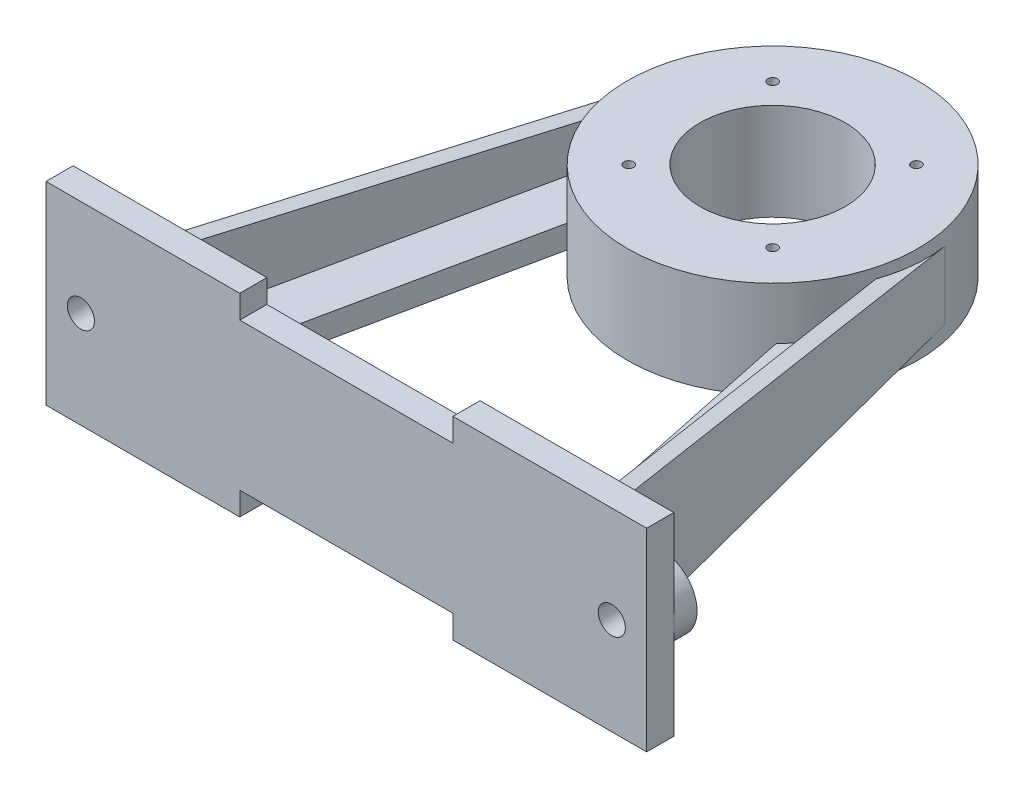
from build123d import *

# Parameters (mm, degrees)
BOSS_EXTRUDE1_DEPTH = 14
SKETCH2_R           = 75
SKETCH2_R_2         = 37.5
BOSS_EXTRUDE2_DEPTH = 25
SKETCH5_W           = 2.5
SKETCH5_H           = 50
CIRPATTERN1_COUNT   = 4
BOSS_EXTRUDE3_DEPTH = 17.5
BOSS_EXTRUDE4_DEPTH = 8
SKETCH9_R           = 7
BOSS_EXTRUDE5_DEPTH = 12
SKETCH10_R          = 7
CUT_EXTRUDE1_DEPTH  = 14
BOSS_EXTRUDE6_DEPTH = 12
FILLET1_R           = 10


with BuildPart() as part:
    # Sketch1 → Boss-Extrude1 (new body)
    with BuildSketch(Plane.XY):
        Polygon((-155, 50), (-55, 50), (-55, 38), (55, 38), (55, 50), (155, 50), (155, -50), (55, -50), (55, -38), (-55, -38), (-55, -50), (-155, -50), align=None)
    extrude(amount=BOSS_EXTRUDE1_DEPTH)



with BuildPart() as body_2:
    # Sketch2 → Boss-Extrude2 (new body, symmetric)
    with BuildSketch(Plane(origin=(0, 0, 0), x_dir=(1, 0, 0), z_dir=(0, 1, 0))):
        with Locations(Location((0, 206, 0), (0, 0, 270))):  # turned: the seam where the file's is
            Circle(SKETCH2_R)
        with Locations(Location((0, 206, 0), (0, 0, 270))):  # turned: the seam where the file's is
            Circle(SKETCH2_R_2, mode=Mode.SUBTRACT)
    extrude(amount=BOSS_EXTRUDE2_DEPTH, both=True)

    # Sketch5 → M6 Tapped Hole1 (revolve, cut)
    with BuildSketch(Plane(origin=(-37.123106012, 25, -243.123106012), x_dir=(0, 0, 1), z_dir=(1, 0, 0))):
        with Locations((1.25, 25)):
            Rectangle(SKETCH5_W, SKETCH5_H)
    m6_tapped_hole1 = revolve(axis=Axis((-37.123106012, 31.35, -243.123106012), (0, -1, 0)), mode=Mode.SUBTRACT)

    # CirPattern1: M6 Tapped Hole1 ×4 about axis
    cirpattern1_axis = Axis((0, 0, -206), (0, 1, 0))
    for i in range(1, CIRPATTERN1_COUNT):
        add(m6_tapped_hole1.rotate(cirpattern1_axis, i * 360 / CIRPATTERN1_COUNT), mode=Mode.SUBTRACT)


with BuildPart() as part_1:
    add(part.part)

    add(body_2.part)  # Boss-Extrude3 merges body 2
    # Sketch7 → Boss-Extrude3 (add, symmetric)
    with BuildSketch(Plane(origin=(0, 0, 0), x_dir=(1, 0, 0), z_dir=(0, 1, 0))):
        with BuildLine():
            Line((-111.824729359, 0), (-120, 0))
            Line((-120, 0), (-73.392065698, 221.446834387))
            ThreePointArc((-73.392065698, 221.446834387), (-74.975422623, 204.08010351), (-72.505303494, 186.81717004))
            Line((-72.505303494, 186.81717004), (-111.824729359, 0))
        make_face()
    boss_extrude3 = extrude(amount=BOSS_EXTRUDE3_DEPTH, both=True)

    # Sketch8 → Boss-Extrude4 (add)
    with BuildSketch(Plane(origin=(-114.909766558, 0, -24.185068462), x_dir=(-0.205957792, 0, 0.978560876), z_dir=(-0.978560876, 0, -0.205957792))):
        Polygon((-201.58354045, 17.5), (24.714935019, 32.5), (24.714935019, 17.5), align=None)
        Polygon((24.714935019, -32.5), (24.714935019, -17.5), (-201.58354045, -17.5), align=None)
    boss_extrude4 = extrude(amount=-BOSS_EXTRUDE4_DEPTH)

    # Sketch9 → Boss-Extrude5 (add)
    with BuildSketch(Plane(origin=(0, 0, 0), x_dir=(-1, 0, 0), z_dir=(0, 0, -1))):
        with BuildLine():
            Line((111.824729359, 18), (111.824729359, -18))
            Line((111.824729359, -18), (137, -18))
            ThreePointArc((137, -18), (155, 0), (137, 18))
            Line((137, 18), (111.824729359, 18))
        make_face()
        with Locations((137, 0)):
            Circle(SKETCH9_R, mode=Mode.SUBTRACT)
    boss_extrude5 = extrude(amount=BOSS_EXTRUDE5_DEPTH)

    # Sketch10 → Cut-Extrude1 (cut)
    with BuildSketch(Plane(origin=(0, 0, 0), x_dir=(-1, 0, 0), z_dir=(0, 0, -1))):
        with Locations((137, 0)):
            Circle(SKETCH10_R)
    cut_extrude1 = extrude(amount=-CUT_EXTRUDE1_DEPTH, mode=Mode.SUBTRACT)

    # Mirror3: Boss-Extrude3, Boss-Extrude4, Boss-Extrude5, Cut-Extrude1 across plane
    add(boss_extrude3.mirror(Plane(origin=(0, 0, 0), x_dir=(0, 0, 1), z_dir=(1, 0, 0))))
    add(boss_extrude4.mirror(Plane(origin=(0, 0, 0), x_dir=(0, 0, 1), z_dir=(1, 0, 0))))
    add(boss_extrude5.mirror(Plane(origin=(0, 0, 0), x_dir=(0, 0, 1), z_dir=(1, 0, 0))))
    add(cut_extrude1.mirror(Plane(origin=(0, 0, 0), x_dir=(0, 0, 1), z_dir=(1, 0, 0))), mode=Mode.SUBTRACT)

    # Sketch13 → Boss-Extrude6 (add)
    with BuildSketch(Plane(origin=(0, -2, 0), x_dir=(1, 0, 0), z_dir=(0, 1, 0))):
        with BuildLine():
            Line((-111.824729359, 0), (-72.505303494, 186.81717004))
            ThreePointArc((-72.505303494, 186.81717004), (-65.31598907, 169.137802944), (-53.897144884, 153.845443407))
            Line((-53.897144884, 153.845443407), (-82.488547055, 18))
            Line((-82.488547055, 18), (82.488547055, 18))
            Line((82.488547055, 18), (53.897144884, 153.845443407))
            ThreePointArc((53.897144884, 153.845443407), (65.31598907, 169.137802944), (72.505303494, 186.81717004))
            Line((72.505303494, 186.81717004), (111.824729359, 0))
            Line((111.824729359, 0), (55, 0))
            Line((55, 0), (-111.824729359, 0))
        make_face()
    extrude(amount=-BOSS_EXTRUDE6_DEPTH)

    # Fillet1
    fillet1_edges = [part_1.edges().sort_by_distance(p)[0] for p in [
        (-82.488547055, -8, -18),
        (82.488547055, -8, -18),
    ]]
    fillet(fillet1_edges, radius=FILLET1_R)


solid = part_1.part
